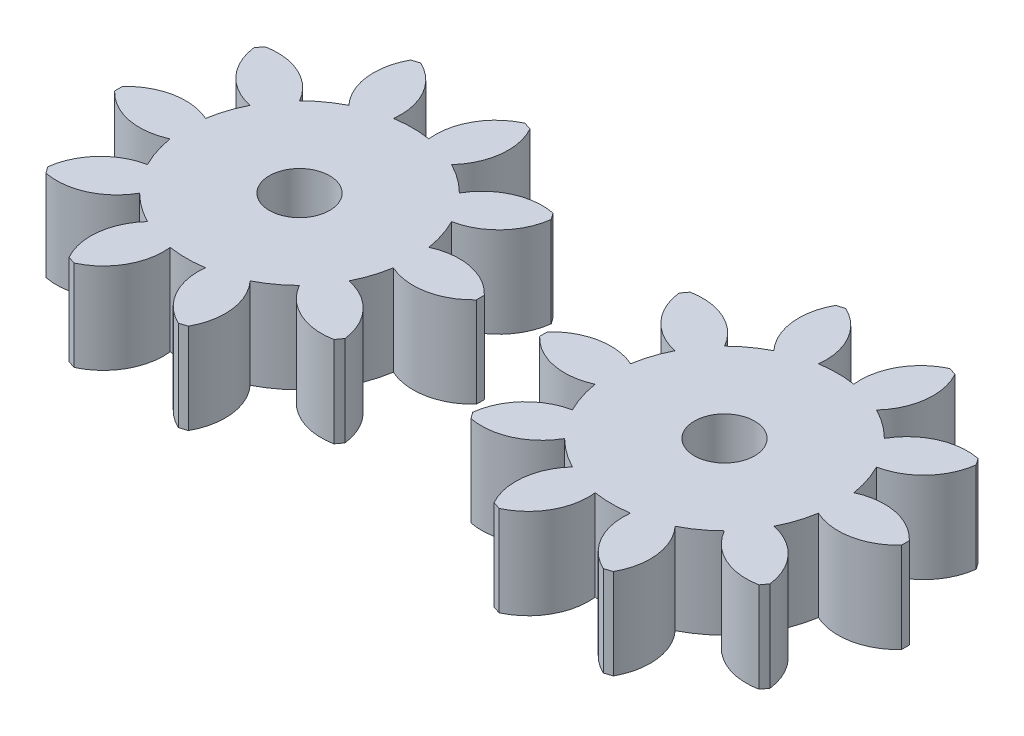
from build123d import *

# Parameters (mm, degrees)
SKETCH2_R             = 4
BOSS_EXTRUDE1_DEPTH   = 12
BOSS_EXTRUDE1_2_DEPTH = 12


with BuildPart() as part:
    # Sketch2 → Boss-Extrude1 (new body)
    with BuildSketch(Plane(origin=(0, 0, 0), x_dir=(1, 0, 0), z_dir=(0, 1, 0))):
        with BuildLine():
            ThreePointArc((39.91929142, 68.654507651), (39.925113633, 69.183121198), (39.91929142, 69.711734744))
            ThreePointArc((39.91929142, 69.711734744), (35.623678248, 72.107813998), (30.738130346, 71.537805219))
            ThreePointArc((30.738130346, 71.537805219), (30.19001032, 73.818067096), (29.293144433, 75.985014574))
            ThreePointArc((29.293144433, 75.985014574), (33.580678467, 78.395520792), (35.647522476, 82.8588877))
            ThreePointArc((35.647522476, 82.8588877), (35.341521498, 83.289967253), (35.026099982, 83.714202385))
            ThreePointArc((35.026099982, 83.714202385), (30.142495876, 83.127773149), (26.52504735, 79.794973354))
            ThreePointArc((26.52504735, 79.794973354), (24.741304632, 81.317567096), (22.742025117, 82.54349989))
            ThreePointArc((22.742025117, 82.54349989), (24.793853009, 87.013789659), (23.842463693, 91.839589767))
            ThreePointArc((23.842463693, 91.839589767), (23.341521498, 92.008477589), (22.836980977, 92.166290906))
            ThreePointArc((22.836980977, 92.166290906), (19.230756718, 88.821349216), (18.263149953, 83.998774648))
            ThreePointArc((18.263149953, 83.998774648), (15.925113633, 84.182121198), (13.587077312, 83.998774648))
            ThreePointArc((13.587077312, 83.998774648), (12.619470547, 88.821349216), (9.013246288, 92.166290906))
            ThreePointArc((9.013246288, 92.166290906), (8.508705768, 92.008477589), (8.007763572, 91.839589767))
            ThreePointArc((8.007763572, 91.839589767), (7.056374256, 87.013789659), (9.108202148, 82.54349989))
            ThreePointArc((9.108202148, 82.54349989), (7.108922633, 81.317567097), (5.325179915, 79.794973354))
            ThreePointArc((5.325179915, 79.794973354), (1.707731389, 83.127773149), (-3.175872717, 83.714202385))
            ThreePointArc((-3.175872717, 83.714202385), (-3.491294233, 83.289967253), (-3.797295211, 82.8588877))
            ThreePointArc((-3.797295211, 82.8588877), (-1.730451202, 78.395520792), (2.557082832, 75.985014575))
            ThreePointArc((2.557082832, 75.985014575), (1.660216945, 73.818067097), (1.112096919, 71.537805219))
            ThreePointArc((1.112096919, 71.537805219), (-3.773450983, 72.107813998), (-8.069064155, 69.711734744))
            ThreePointArc((-8.069064155, 69.711734744), (-8.074886368, 69.183121198), (-8.069064155, 68.654507651))
            ThreePointArc((-8.069064155, 68.654507651), (-3.773450983, 66.258428398), (1.112096919, 66.828437177))
            ThreePointArc((1.112096919, 66.828437177), (1.660216945, 64.548175299), (2.557082832, 62.381227821))
            ThreePointArc((2.557082832, 62.381227821), (-1.730451202, 59.970721604), (-3.797295211, 55.507354696))
            ThreePointArc((-3.797295211, 55.507354696), (-3.491294233, 55.076275143), (-3.175872717, 54.652040011))
            ThreePointArc((-3.175872717, 54.652040011), (1.707731389, 55.238469247), (5.325179915, 58.571269042))
            ThreePointArc((5.325179915, 58.571269042), (7.108922633, 57.048675299), (9.108202148, 55.822742505))
            ThreePointArc((9.108202148, 55.822742505), (7.056374256, 51.352452737), (8.007763572, 46.526652629))
            ThreePointArc((8.007763572, 46.526652629), (8.508705768, 46.357764807), (9.013246288, 46.19995149))
            ThreePointArc((9.013246288, 46.19995149), (12.619470547, 49.54489318), (13.587077312, 54.367467747))
            ThreePointArc((13.587077312, 54.367467747), (15.925113633, 54.184121198), (18.263149953, 54.367467747))
            ThreePointArc((18.263149953, 54.367467747), (19.230756718, 49.54489318), (22.836980977, 46.19995149))
            ThreePointArc((22.836980977, 46.19995149), (23.341521498, 46.357764807), (23.842463693, 46.526652629))
            ThreePointArc((23.842463693, 46.526652629), (24.793853009, 51.352452737), (22.742025117, 55.822742505))
            ThreePointArc((22.742025117, 55.822742505), (24.741304632, 57.048675299), (26.52504735, 58.571269042))
            ThreePointArc((26.52504735, 58.571269042), (30.142495876, 55.238469247), (35.026099982, 54.652040011))
            ThreePointArc((35.026099982, 54.652040011), (35.341521498, 55.076275143), (35.647522476, 55.507354696))
            ThreePointArc((35.647522476, 55.507354696), (33.580678467, 59.970721604), (29.293144433, 62.381227821))
            ThreePointArc((29.293144433, 62.381227821), (30.19001032, 64.548175299), (30.738130346, 66.828437177))
            ThreePointArc((30.738130346, 66.828437177), (35.623678248, 66.258428398), (39.91929142, 68.654507651))
        make_face()
        with Locations(Location((15.925113633, 69.183121198, 0), (0, 0, 270))):  # turned: the seam where the file's is
            Circle(SKETCH2_R, mode=Mode.SUBTRACT)
    extrude(amount=BOSS_EXTRUDE1_DEPTH)


with BuildPart() as body_2:
    # Sketch2 → Boss-Extrude1 2 (new body)
    with BuildSketch(Plane(origin=(0, 0, 0), x_dir=(1, 0, 0), z_dir=(0, 1, 0))):
        with BuildLine():
            ThreePointArc((96.30636676, 68.654507651), (96.312188972, 69.183121198), (96.30636676, 69.711734744))
            ThreePointArc((96.30636676, 69.711734744), (92.010753588, 72.107813998), (87.125205686, 71.537805219))
            ThreePointArc((87.125205686, 71.537805219), (86.57708566, 73.818067096), (85.680219773, 75.985014574))
            ThreePointArc((85.680219773, 75.985014574), (89.967753806, 78.395520792), (92.034597815, 82.8588877))
            ThreePointArc((92.034597815, 82.8588877), (91.728596837, 83.289967253), (91.413175321, 83.714202385))
            ThreePointArc((91.413175321, 83.714202385), (86.529571216, 83.127773149), (82.91212269, 79.794973354))
            ThreePointArc((82.91212269, 79.794973354), (81.128379971, 81.317567096), (79.129100457, 82.54349989))
            ThreePointArc((79.129100457, 82.54349989), (81.180928348, 87.013789659), (80.229539032, 91.839589767))
            ThreePointArc((80.229539032, 91.839589767), (79.728596837, 92.008477589), (79.224056316, 92.166290906))
            ThreePointArc((79.224056316, 92.166290906), (75.617832057, 88.821349216), (74.650225292, 83.998774648))
            ThreePointArc((74.650225292, 83.998774648), (72.312188972, 84.182121198), (69.974152652, 83.998774648))
            ThreePointArc((69.974152652, 83.998774648), (69.006545886, 88.821349216), (65.400321627, 92.166290906))
            ThreePointArc((65.400321627, 92.166290906), (64.895781107, 92.008477589), (64.394838911, 91.839589767))
            ThreePointArc((64.394838911, 91.839589767), (63.443449595, 87.013789659), (65.495277487, 82.54349989))
            ThreePointArc((65.495277487, 82.54349989), (63.495997973, 81.317567097), (61.712255254, 79.794973354))
            ThreePointArc((61.712255254, 79.794973354), (58.094806728, 83.127773149), (53.211202622, 83.714202385))
            ThreePointArc((53.211202622, 83.714202385), (52.895781107, 83.289967253), (52.589780128, 82.8588877))
            ThreePointArc((52.589780128, 82.8588877), (54.656624137, 78.395520792), (58.944158171, 75.985014575))
            ThreePointArc((58.944158171, 75.985014575), (58.047292284, 73.818067097), (57.499172258, 71.537805219))
            ThreePointArc((57.499172258, 71.537805219), (52.613624356, 72.107813998), (48.318011184, 69.711734744))
            ThreePointArc((48.318011184, 69.711734744), (48.312188972, 69.183121198), (48.318011184, 68.654507651))
            ThreePointArc((48.318011184, 68.654507651), (52.613624356, 66.258428398), (57.499172258, 66.828437177))
            ThreePointArc((57.499172258, 66.828437177), (58.047292284, 64.548175299), (58.944158171, 62.381227821))
            ThreePointArc((58.944158171, 62.381227821), (54.656624137, 59.970721604), (52.589780128, 55.507354696))
            ThreePointArc((52.589780128, 55.507354696), (52.895781107, 55.076275143), (53.211202622, 54.652040011))
            ThreePointArc((53.211202622, 54.652040011), (58.094806728, 55.238469247), (61.712255254, 58.571269042))
            ThreePointArc((61.712255254, 58.571269042), (63.495997973, 57.048675299), (65.495277487, 55.822742505))
            ThreePointArc((65.495277487, 55.822742505), (63.443449595, 51.352452737), (64.394838911, 46.526652629))
            ThreePointArc((64.394838911, 46.526652629), (64.895781107, 46.357764807), (65.400321627, 46.19995149))
            ThreePointArc((65.400321627, 46.19995149), (69.006545886, 49.54489318), (69.974152652, 54.367467747))
            ThreePointArc((69.974152652, 54.367467747), (72.312188972, 54.184121198), (74.650225292, 54.367467747))
            ThreePointArc((74.650225292, 54.367467747), (75.617832058, 49.54489318), (79.224056316, 46.19995149))
            ThreePointArc((79.224056316, 46.19995149), (79.728596837, 46.357764807), (80.229539032, 46.526652629))
            ThreePointArc((80.229539032, 46.526652629), (81.180928348, 51.352452737), (79.129100457, 55.822742505))
            ThreePointArc((79.129100457, 55.822742505), (81.128379971, 57.048675299), (82.91212269, 58.571269042))
            ThreePointArc((82.91212269, 58.571269042), (86.529571216, 55.238469247), (91.413175322, 54.652040011))
            ThreePointArc((91.413175322, 54.652040011), (91.728596837, 55.076275143), (92.034597815, 55.507354696))
            ThreePointArc((92.034597815, 55.507354696), (89.967753806, 59.970721604), (85.680219773, 62.381227821))
            ThreePointArc((85.680219773, 62.381227821), (86.57708566, 64.548175299), (87.125205686, 66.828437177))
            ThreePointArc((87.125205686, 66.828437177), (92.010753588, 66.258428398), (96.30636676, 68.654507651))
        make_face()
        with Locations(Location((72.312188972, 69.183121198, 0), (0, 0, 270))):  # turned: the seam where the file's is
            Circle(SKETCH2_R, mode=Mode.SUBTRACT)
    extrude(amount=BOSS_EXTRUDE1_2_DEPTH)


solid = Compound([part.part, body_2.part])
